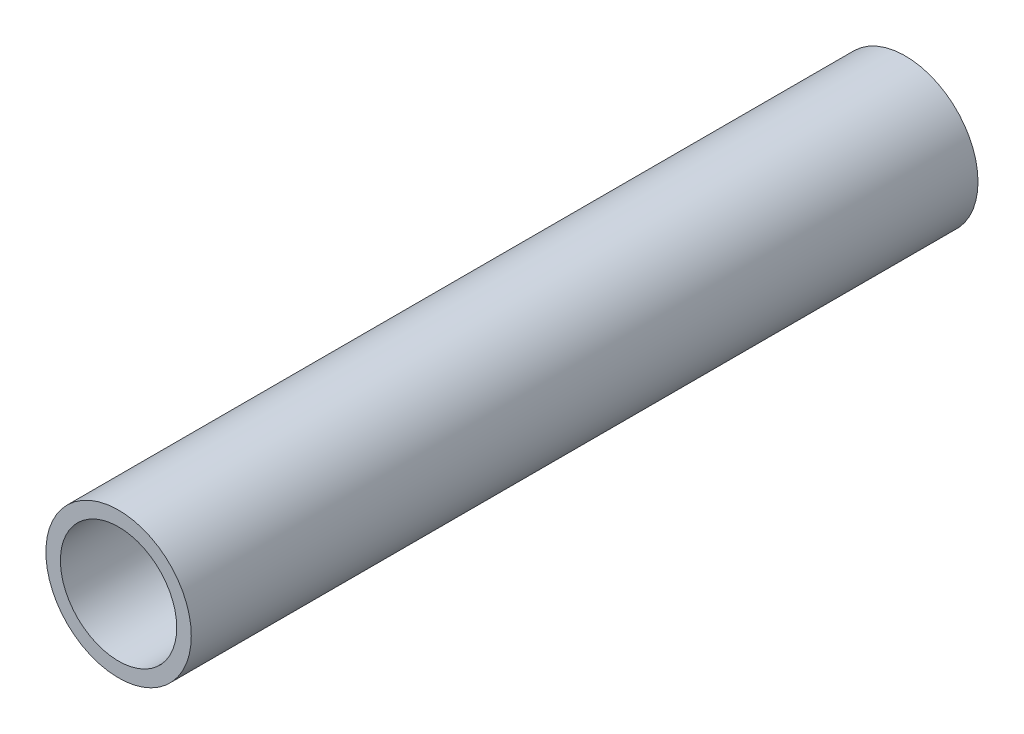
from build123d import *

# Parameters (mm, degrees)
SKETCH1_R           = 1.25
SKETCH1_R_2         = 1
BOSS_EXTRUDE1_DEPTH = 13.525


with BuildPart() as part:
    # Sketch1 → Boss-Extrude1 (new body)
    with BuildSketch(Plane.XY):
        Circle(SKETCH1_R)
        Circle(SKETCH1_R_2, mode=Mode.SUBTRACT)
    extrude(amount=BOSS_EXTRUDE1_DEPTH)


solid = part.part
